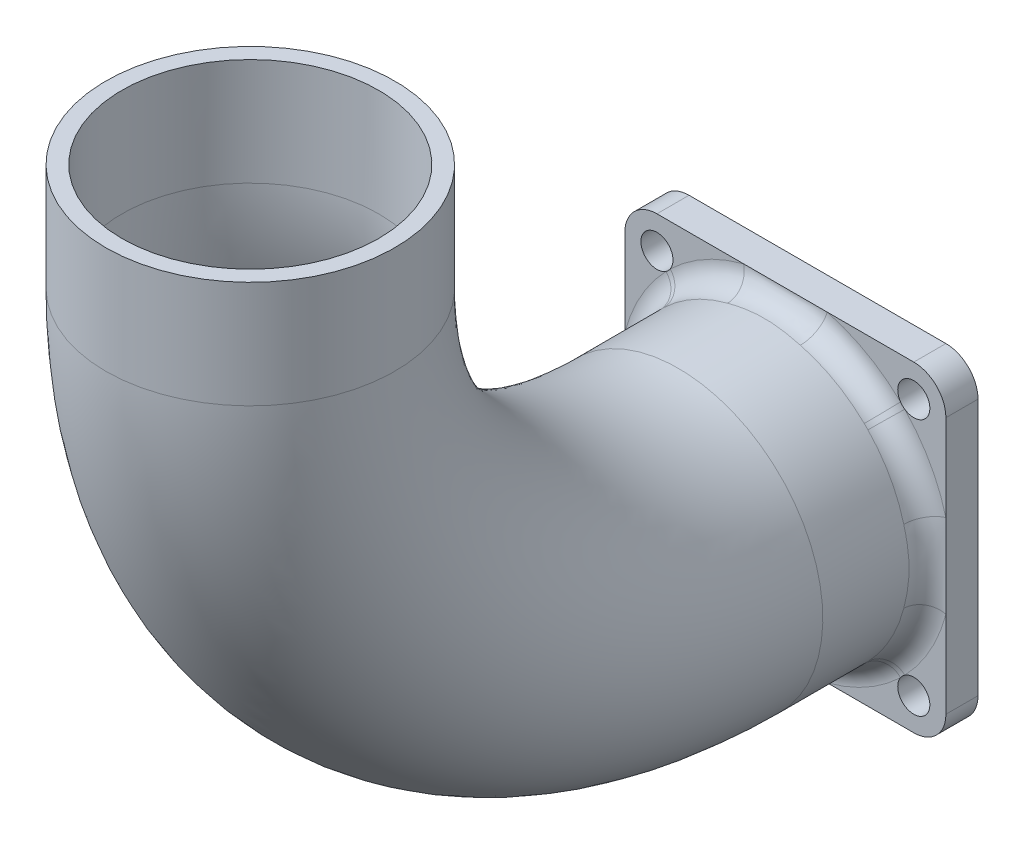
from build123d import *

# Parameters (mm, degrees)
ESQUISSE1_W        = 30
ESQUISSE1_H        = 30
ESQUISSE1_R        = 12
ESQUISSE1_R_2      = 1.5
BOSS_EXTRU_1_DEPTH = 3
ESQUISSE4_R        = 13.5
ESQUISSE4_R_2      = 12
CONG_1_R           = 2
CONG_2_R           = 3


with BuildPart() as part:
    # Esquisse1 → Boss.-Extru.1 (new body)
    with BuildSketch(Plane.XY):
        Rectangle(ESQUISSE1_W, ESQUISSE1_H)
        Circle(ESQUISSE1_R, mode=Mode.SUBTRACT)
        with Locations((-12, 12)):
            Circle(ESQUISSE1_R_2, mode=Mode.SUBTRACT)
        with Locations((12, 12)):
            Circle(ESQUISSE1_R_2, mode=Mode.SUBTRACT)
        with Locations((12, -12)):
            Circle(ESQUISSE1_R_2, mode=Mode.SUBTRACT)
        with Locations((-12, -12)):
            Circle(ESQUISSE1_R_2, mode=Mode.SUBTRACT)
    extrude(amount=BOSS_EXTRU_1_DEPTH)

    # Balayage-Mince1: sweep along a path in Esquisse2
    with BuildLine(Plane(origin=(0, 0, 0), x_dir=(0, 0, -1), z_dir=(1, 0, 0))) as balayage_mince1_path:
        Line((-3, 0), (-13, 0))
        ThreePointArc((-13, 0), (-41.284271247, 11.715728753), (-53, 40))
        Line((-53, 40), (-53, 50))
    # Esquisse4 → Balayage-Mince1 (sweep)
    with BuildSketch(Plane.XY.offset(3)):
        Circle(ESQUISSE4_R)
        Circle(ESQUISSE4_R_2, mode=Mode.SUBTRACT)
    sweep(path=balayage_mince1_path.line)

    # Congé1
    cong_1_edges = [part.edges().sort_by_distance(p)[0] for p in [
        (-13.5, 0, 3),
    ]]
    fillet(cong_1_edges, radius=CONG_1_R)

    # Congé2
    cong_2_edges = [part.edges().sort_by_distance(p)[0] for p in [
        (15, -15, 1.5),
        (-15, -15, 1.5),
        (-15, 15, 1.5),
        (15, 15, 1.5),
    ]]
    fillet(cong_2_edges, radius=CONG_2_R)


solid = part.part
